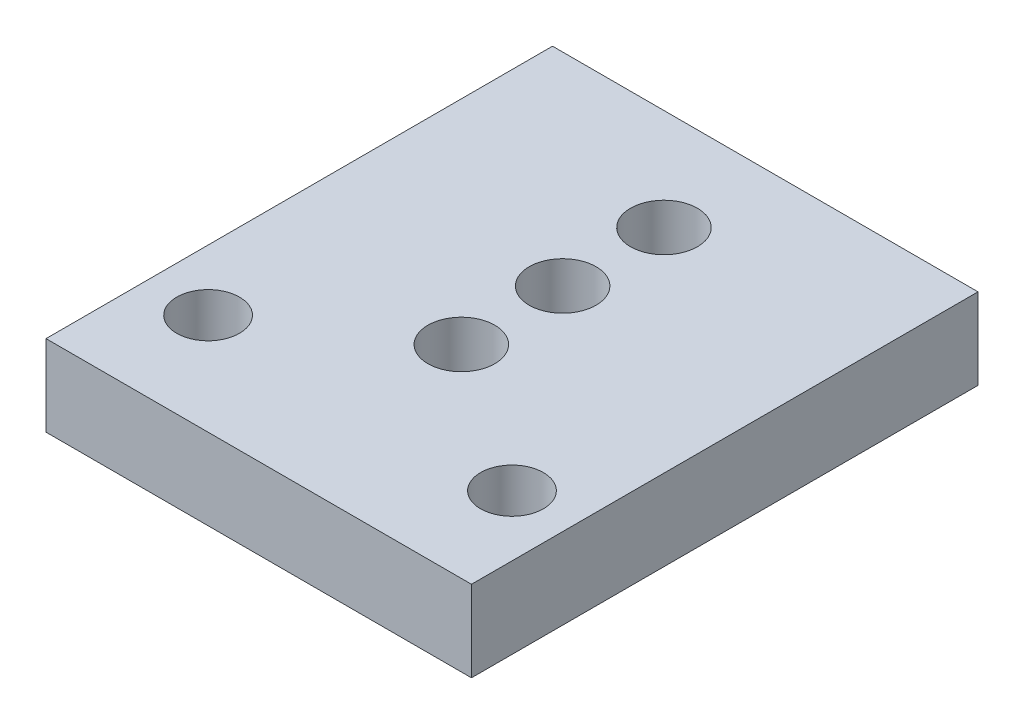
from build123d import *

# Parameters (mm, degrees)
SKETCH1_W                      = 21
SKETCH1_H                      = 25
BOSS_EXTRUDE1_DEPTH            = 4
F_3_1_3_1_DIAMETER_HOLE1_D     = 3.1
F_3_1_3_1_DIAMETER_HOLE1_DEPTH = 10
F_3_1_3_1_DIAMETER_HOLE1_TIP   = 0.931333959
M4X0_7_TAPPED_HOLE1_D          = 3.3


with BuildPart() as part:
    # Sketch1 → Boss-Extrude1 (new body)
    with BuildSketch(Plane(origin=(0, 0, 0), x_dir=(1, 0, 0), z_dir=(0, 1, 0))):
        with Locations((10.5, 12.5)):
            Rectangle(SKETCH1_W, SKETCH1_H)
    extrude(amount=BOSS_EXTRUDE1_DEPTH)

    # Ø3.1 (3.1) Diameter Hole1
    with Locations(Plane(origin=(0, 4, 0), x_dir=(1, 0, 0), z_dir=(0, 1, 0))):
        with Locations((3, 5), (18, 5)):
            Hole(F_3_1_3_1_DIAMETER_HOLE1_D / 2, depth=F_3_1_3_1_DIAMETER_HOLE1_DEPTH)
            with Locations((0, 0, -(F_3_1_3_1_DIAMETER_HOLE1_DEPTH + F_3_1_3_1_DIAMETER_HOLE1_TIP / 2))):  # 118° drill point
                Cone(0, F_3_1_3_1_DIAMETER_HOLE1_D / 2, F_3_1_3_1_DIAMETER_HOLE1_TIP, mode=Mode.SUBTRACT)

    # M4x0.7 Tapped Hole1 (through all)
    with Locations(Plane(origin=(0, 4, 0), x_dir=(1, 0, 0), z_dir=(0, 1, 0))):
        with Locations((10.5, 10), (10.5, 20), (10.5, 15)):
            Hole(M4X0_7_TAPPED_HOLE1_D / 2)


solid = part.part
